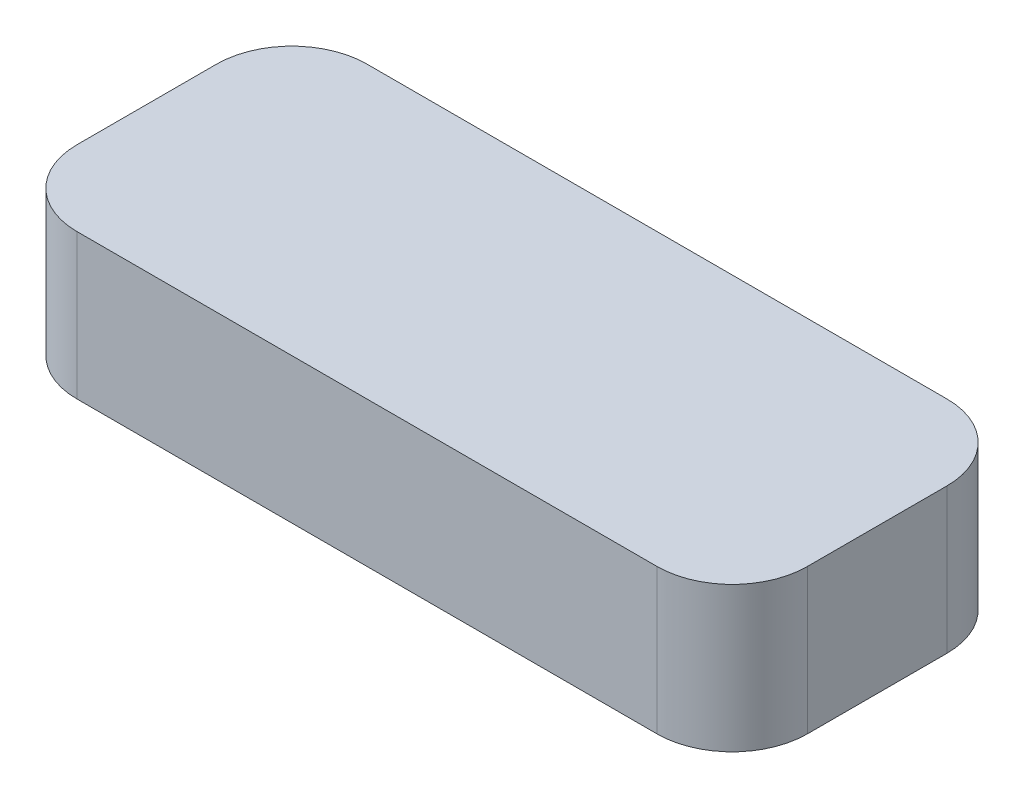
from build123d import *

# Parameters (mm, degrees)
SKETCH1_W           = 431.8
SKETCH1_H           = 171.45
BOSS_EXTRUDE1_DEPTH = 85.725
CUT_EXTRUDE1_DEPTH  = 73.025
FILLET3_R           = 44.45


with BuildPart() as part:
    # Sketch1 → Boss-Extrude1 (new body)
    with BuildSketch(Plane(origin=(0, 0, 0), x_dir=(1, 0, 0), z_dir=(0, 1, 0))):
        Rectangle(SKETCH1_W, SKETCH1_H)
    extrude(amount=BOSS_EXTRUDE1_DEPTH)

    # Sketch2 → Cut-Extrude1 (cut)
    with BuildSketch(Plane.XZ):
        with BuildLine():
            Line((162.16885638, 76.686434381), (-162.16885638, 76.686434381))
            ThreePointArc((-162.16885638, 76.686434381), (-193.771281353, 63.596281353), (-206.861434381, 31.99385638))
            Line((-206.861434381, 31.99385638), (-206.861434381, -31.99385638))
            ThreePointArc((-206.861434381, -31.99385638), (-193.771281353, -63.596281353), (-162.16885638, -76.686434381))
            Line((-162.16885638, -76.686434381), (162.16885638, -76.686434381))
            ThreePointArc((162.16885638, -76.686434381), (193.771281353, -63.596281353), (206.861434381, -31.99385638))
            Line((206.861434381, -31.99385638), (206.861434381, 31.99385638))
            ThreePointArc((206.861434381, 31.99385638), (193.771281353, 63.596281353), (162.16885638, 76.686434381))
        make_face()
    extrude(amount=-CUT_EXTRUDE1_DEPTH, mode=Mode.SUBTRACT)

    # Fillet3
    fillet3_edges = [part.edges().sort_by_distance(p)[0] for p in [
        (215.9, 42.8625, 85.725),
        (-215.9, 42.8625, 85.725),
        (-215.9, 42.8625, -85.725),
        (215.9, 42.8625, -85.725),
    ]]
    fillet(fillet3_edges, radius=FILLET3_R)


solid = part.part
